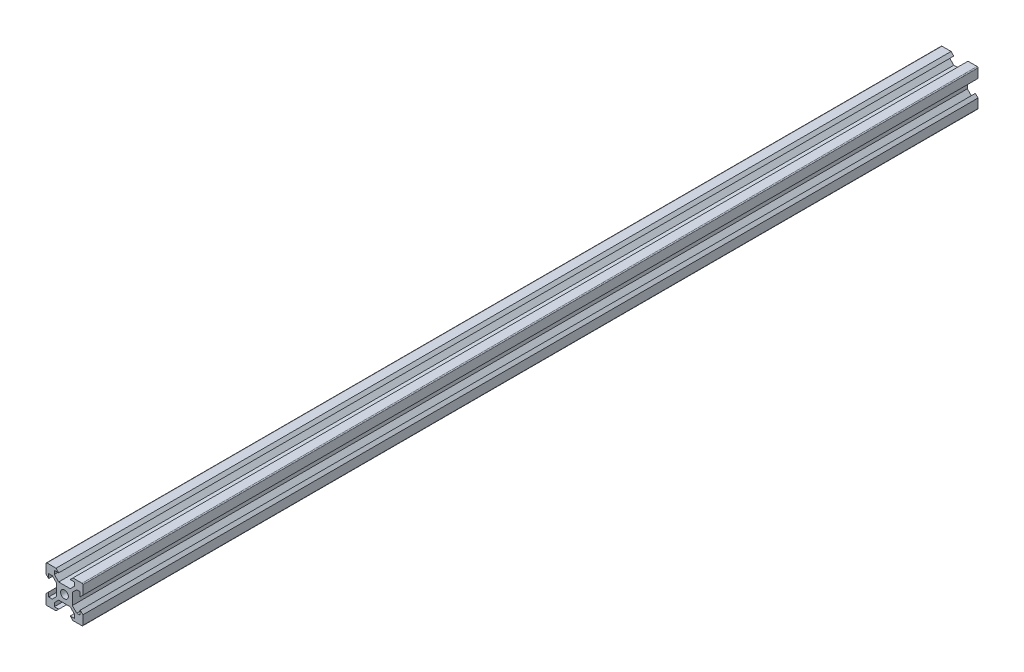
from build123d import *

# Parameters (mm, degrees)
SKETCH1_R           = 2.1
BOSS_EXTRUDE1_DEPTH = 485
CUT_EXTRUDE1_REACH  = 16.245
SKETCH2_R           = 1.5


with BuildPart() as part:
    # Sketch1 → Boss-Extrude1 (new body)
    with BuildSketch(Plane.XY):
        with BuildLine():
            Line((-3.125, 4.245), (3.125, 4.245))
            Line((3.125, 4.245), (5.5, 6.62))
            Line((5.5, 6.62), (5.5, 8.545))
            Line((5.5, 8.545), (3.125, 8.545))
            Line((3.125, 8.545), (4.58, 10))
            Line((4.58, 10), (9.5, 10))
            ThreePointArc((9.5, 10), (9.853553391, 9.853553391), (10, 9.5))
            Line((10, 9.5), (10, 4.58))
            Line((10, 4.58), (8.545, 3.125))
            Line((8.545, 3.125), (8.545, 5.5))
            Line((8.545, 5.5), (6.62, 5.5))
            Line((6.62, 5.5), (4.245, 3.125))
            Line((4.245, 3.125), (4.245, -3.125))
            Line((4.245, -3.125), (6.62, -5.5))
            Line((6.62, -5.5), (8.545, -5.5))
            Line((8.545, -5.5), (8.545, -3.125))
            Line((8.545, -3.125), (10, -4.58))
            Line((10, -4.58), (10, -9.5))
            ThreePointArc((10, -9.5), (9.853553391, -9.853553391), (9.5, -10))
            Line((9.5, -10), (4.58, -10))
            Line((4.58, -10), (3.125, -8.545))
            Line((3.125, -8.545), (5.5, -8.545))
            Line((5.5, -8.545), (5.5, -6.62))
            Line((5.5, -6.62), (3.125, -4.245))
            Line((3.125, -4.245), (-3.125, -4.245))
            Line((-3.125, -4.245), (-5.5, -6.62))
            Line((-5.5, -6.62), (-5.5, -8.545))
            Line((-5.5, -8.545), (-3.125, -8.545))
            Line((-3.125, -8.545), (-4.58, -10))
            Line((-4.58, -10), (-9.5, -10))
            ThreePointArc((-9.5, -10), (-9.853553391, -9.853553391), (-10, -9.5))
            Line((-10, -9.5), (-10, -4.58))
            Line((-10, -4.58), (-8.545, -3.125))
            Line((-8.545, -3.125), (-8.545, -5.5))
            Line((-8.545, -5.5), (-6.62, -5.5))
            Line((-6.62, -5.5), (-4.245, -3.125))
            Line((-4.245, -3.125), (-4.245, 3.125))
            Line((-4.245, 3.125), (-6.62, 5.5))
            Line((-6.62, 5.5), (-8.545, 5.5))
            Line((-8.545, 5.5), (-8.545, 3.125))
            Line((-8.545, 3.125), (-10, 4.58))
            Line((-10, 4.58), (-10, 9.5))
            ThreePointArc((-10, 9.5), (-9.853553391, 9.853553391), (-9.5, 10))
            Line((-9.5, 10), (-4.58, 10))
            Line((-4.58, 10), (-3.125, 8.545))
            Line((-3.125, 8.545), (-5.5, 8.545))
            Line((-5.5, 8.545), (-5.5, 6.62))
            Line((-5.5, 6.62), (-3.125, 4.245))
        make_face()
        Circle(SKETCH1_R, mode=Mode.SUBTRACT)
    extrude(amount=BOSS_EXTRUDE1_DEPTH)

    # Sketch2 → Cut-Extrude1 (cut, up to next)
    with BuildSketch(Plane.ZY.offset(4.245), mode=Mode.PRIVATE) as cut_extrude1_sk1:
        with Locations((8, 0)):
            Circle(SKETCH2_R)
    cut_extrude1_tool1 = extrude(cut_extrude1_sk1.sketch, amount=-CUT_EXTRUDE1_REACH, mode=Mode.PRIVATE) & part.part
    add(cut_extrude1_tool1.solids().sort_by_distance((-4.245, 0, 8))[0], mode=Mode.SUBTRACT)
    # Sketch2 → Cut-Extrude1 (cut, up to next)
    with BuildSketch(Plane.ZY.offset(4.245), mode=Mode.PRIVATE) as cut_extrude1_sk2:
        with Locations((478.45, 0)):
            Circle(SKETCH2_R)
    cut_extrude1_tool2 = extrude(cut_extrude1_sk2.sketch, amount=-CUT_EXTRUDE1_REACH, mode=Mode.PRIVATE) & part.part
    add(cut_extrude1_tool2.solids().sort_by_distance((-4.245, 0, 478.45))[0], mode=Mode.SUBTRACT)
    # Sketch2 → Cut-Extrude1 (cut, up to next)
    with BuildSketch(Plane.ZY.offset(4.245), mode=Mode.PRIVATE) as cut_extrude1_sk3:
        with Locations((68.5, 0)):
            Circle(SKETCH2_R)
    cut_extrude1_tool3 = extrude(cut_extrude1_sk3.sketch, amount=-CUT_EXTRUDE1_REACH, mode=Mode.PRIVATE) & part.part
    add(cut_extrude1_tool3.solids().sort_by_distance((-4.245, 0, 68.5))[0], mode=Mode.SUBTRACT)
    # Sketch2 → Cut-Extrude1 (cut, up to next)
    with BuildSketch(Plane.ZY.offset(4.245), mode=Mode.PRIVATE) as cut_extrude1_sk4:
        with Locations((417.95, 0)):
            Circle(SKETCH2_R)
    cut_extrude1_tool4 = extrude(cut_extrude1_sk4.sketch, amount=-CUT_EXTRUDE1_REACH, mode=Mode.PRIVATE) & part.part
    add(cut_extrude1_tool4.solids().sort_by_distance((-4.245, 0, 417.95))[0], mode=Mode.SUBTRACT)


solid = part.part
